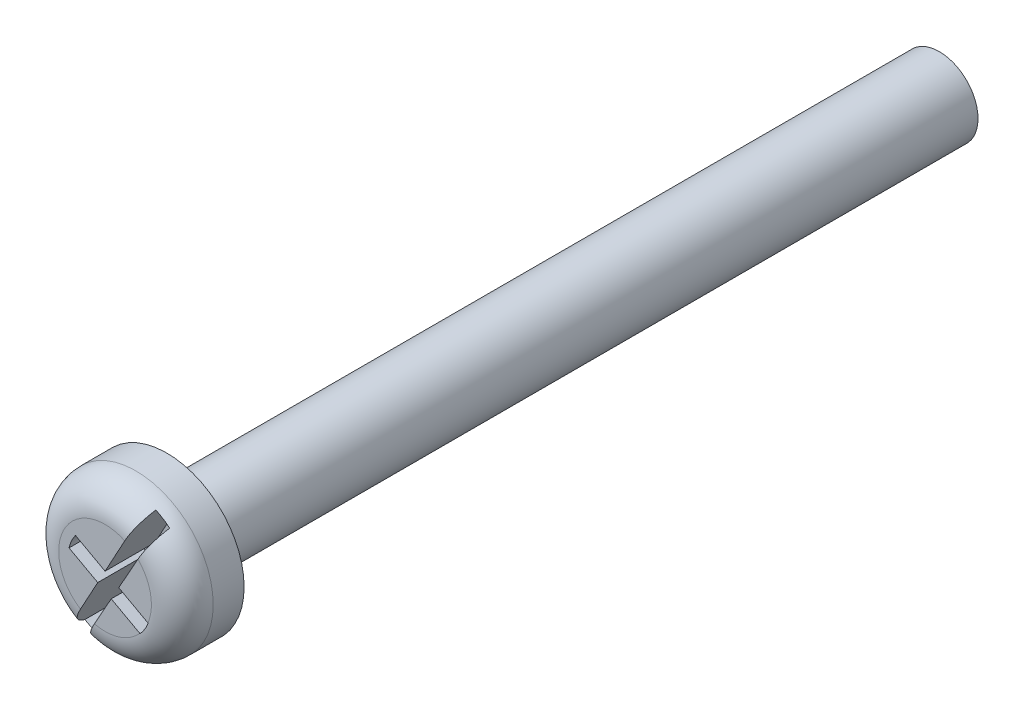
from build123d import *

# Parameters (mm, degrees)
SZKIC1_R                    = 3
DODANIE_WYCI_GNI_CIE2_DEPTH = 2.4
SZKIC2_R                    = 1.5
DODANIE_WYCI_GNI_CIE3_DEPTH = 30
ZAOKR_GLENIE2_R             = 1.2
WYTNIJ_WYCI_GNI_CIE1_DEPTH  = 1.94


with BuildPart() as part:
    # Szkic1 → Dodanie-wyciągnięcie2 (new body)
    with BuildSketch(Plane.XY):
        with Locations((-1.860516246, 2.732142857)):
            Circle(SZKIC1_R)
    extrude(amount=DODANIE_WYCI_GNI_CIE2_DEPTH)

    # Szkic2 → Dodanie-wyciągnięcie3 (add)
    with BuildSketch(Plane(origin=(0, 0, 0), x_dir=(-1, 0, 0), z_dir=(0, 0, -1))):
        with Locations((1.860516246, 2.732142857)):
            Circle(SZKIC2_R)
    extrude(amount=DODANIE_WYCI_GNI_CIE3_DEPTH)

    # Zaokrąglenie2
    zaokr_glenie2_edges = [part.edges().sort_by_distance(p)[0] for p in [
        (-4.860516246, 2.732142857, 2.4),
    ]]
    fillet(zaokr_glenie2_edges, radius=ZAOKR_GLENIE2_R)

    # Szkic3 → Wytnij-wyciągnięcie1 (cut)
    with BuildSketch(Plane.XY.offset(2.4)):
        with BuildLine():
            Line((-1.859548318, 2.959091853), (-0.575649693, 5.316481314))
            ThreePointArc((-0.575649693, 5.316481314), (-0.297886623, 5.158637444), (-0.039271083, 4.97106076))
            Line((-0.039271083, 4.97106076), (-1.329373025, 2.669425378))
            Line((-1.329373025, 2.669425378), (-0.183967515, 2.043621837))
            ThreePointArc((-0.183967515, 2.043621837), (-0.320475658, 1.776553075), (-0.499159616, 1.535654258))
            Line((-0.499159616, 1.535654258), (-1.621312108, 2.148584891))
            Line((-1.621312108, 2.148584891), (-2.819933608, 0.01015725))
            ThreePointArc((-2.819933608, 0.01015725), (-3.083174674, 0.117799023), (-3.33454353, 0.250826496))
            Line((-3.33454353, 0.250826496), (-2.145142944, 2.434706401))
            Line((-2.145142944, 2.434706401), (-3.258687897, 3.042935511))
            ThreePointArc((-3.258687897, 3.042935511), (-3.162842423, 3.328316127), (-3.009463836, 3.587359481))
            Line((-3.009463836, 3.587359481), (-1.859548318, 2.959091853))
        make_face()
    extrude(amount=-WYTNIJ_WYCI_GNI_CIE1_DEPTH, mode=Mode.SUBTRACT)


solid = part.part
